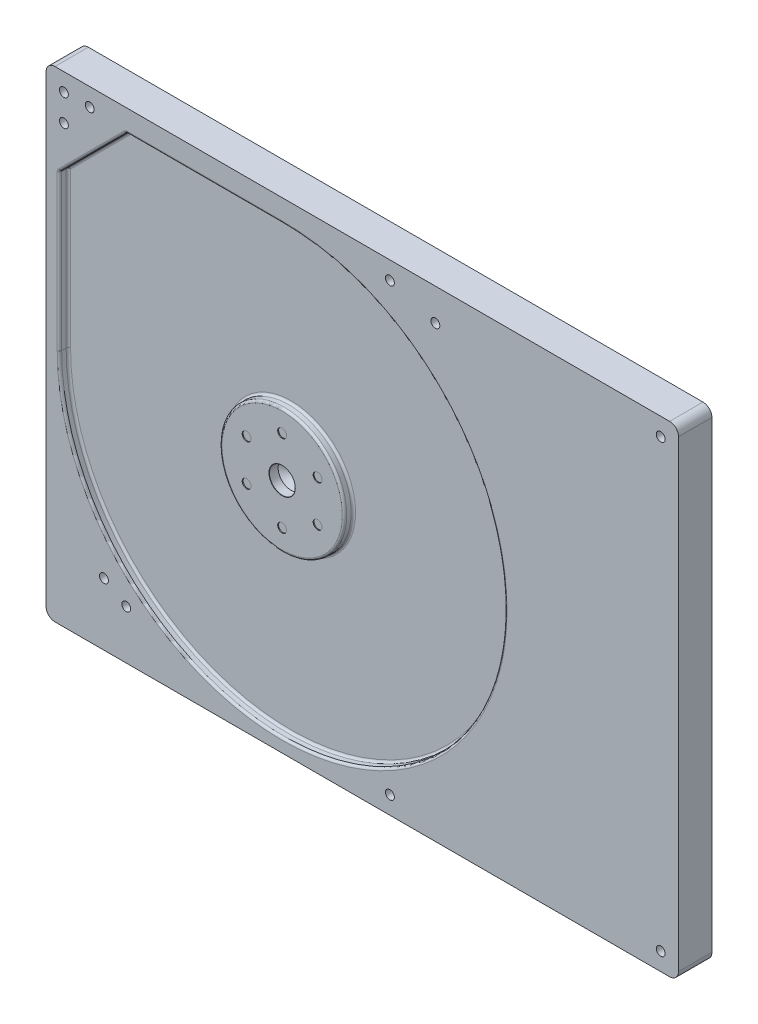
from build123d import *

# Parameters (mm, degrees)
SKETCH1_W                        = 71
SKETCH1_H                        = 54
BOSS_EXTRUDE1_DEPTH              = 3.75
FILLET1_R                        = 1
SKETCH2_R                        = 7
CUT_EXTRUDE1_DEPTH               = 1
FILLET2_R                        = 0.25
SKETCH3_R                        = 0.5
CUT_EXTRUDE2_DEPTH               = 0.1
FILLET3_R                        = 0.25
M2_5_CLEARANCE_HOLE1_D           = 2.9
M2_5_CLEARANCE_HOLE1_DEPTH       = 1
M2_5_CLEARANCE_HOLE1_CSINK_D     = 2.95
M2_5_CLEARANCE_HOLE1_CSINK_ANGLE = 90
M2_5_CLEARANCE_HOLE1_TIP         = 0.871247898
M1_6_CLEARANCE_HOLE1_D           = 1


with BuildPart() as part:
    # Sketch1 → Boss-Extrude1 (new body)
    with BuildSketch(Plane.XY):
        Rectangle(SKETCH1_W, SKETCH1_H)
    extrude(amount=BOSS_EXTRUDE1_DEPTH)

    # Fillet1
    fillet1_edges = [part.edges().sort_by_distance(p)[0] for p in [
        (35.5, -27, 1.875),
        (-35.5, -27, 1.875),
        (-35.5, 27, 1.875),
        (35.5, 27, 1.875),
    ]]
    fillet(fillet1_edges, radius=FILLET1_R)

    # Sketch2 → Cut-Extrude1 (cut)
    with BuildSketch(Plane.XY.offset(3.75)):
        with BuildLine():
            Line((-34, -0.5), (-34, 17))
            Line((-34, 17), (-26.5, 24.5))
            Line((-26.5, 24.5), (-9, 24.5))
            ThreePointArc((-9, 24.5), (8.67766953, -18.17766953), (-34, -0.5))
        make_face()
        with Locations((-9, -0.5)):
            Circle(SKETCH2_R, mode=Mode.SUBTRACT)
    extrude(amount=-CUT_EXTRUDE1_DEPTH, mode=Mode.SUBTRACT)

    # Fillet2
    fillet2_edges = [part.edges().sort_by_distance(p)[0] for p in [
        (-16, -0.5, 3.75),
    ]]
    fillet(fillet2_edges, radius=FILLET2_R)

    # Sketch3 → Cut-Extrude2 (cut)
    with BuildSketch(Plane.XY.offset(3.75)):
        with Locations((-9, 4.1)):
            Circle(SKETCH3_R)
        with Locations((-12.983716857, 1.8)):
            Circle(SKETCH3_R)
        with Locations((-12.983716857, -2.8)):
            Circle(SKETCH3_R)
        with Locations((-9, -5.1)):
            Circle(SKETCH3_R)
        with Locations((-5.016283143, -2.8)):
            Circle(SKETCH3_R)
        with Locations((-5.016283143, 1.8)):
            Circle(SKETCH3_R)
    extrude(amount=-CUT_EXTRUDE2_DEPTH, mode=Mode.SUBTRACT)

    # Fillet3
    fillet3_edges = [part.edges().sort_by_distance(p)[0] for p in [
        (8.67766953, -18.17766953, 2.75),
        (-34, 8.25, 2.75),
        (-30.25, 20.75, 2.75),
        (-34, 17, 3.25),
        (-17.75, 24.5, 2.75),
        (-26.5, 24.5, 3.25),
        (-16, -0.5, 2.75),
        (8.67766953, -18.17766953, 3.75),
        (-17.75, 24.5, 3.75),
        (-30.25, 20.75, 3.75),
        (-34, 8.25, 3.75),
    ]]
    fillet(fillet3_edges, radius=FILLET3_R)

    # M2.5 Clearance Hole1
    with Locations(Plane.XY.offset(3.75)):
        with Locations((-9, -0.5)):
            CounterSinkHole(M2_5_CLEARANCE_HOLE1_D / 2, M2_5_CLEARANCE_HOLE1_CSINK_D / 2, depth=M2_5_CLEARANCE_HOLE1_DEPTH, counter_sink_angle=M2_5_CLEARANCE_HOLE1_CSINK_ANGLE)
            with Locations((0, 0, -(M2_5_CLEARANCE_HOLE1_DEPTH + M2_5_CLEARANCE_HOLE1_TIP / 2))):  # 118° drill point
                Cone(0, M2_5_CLEARANCE_HOLE1_D / 2, M2_5_CLEARANCE_HOLE1_TIP, mode=Mode.SUBTRACT)

    # M1.6 Clearance Hole1 (through all)
    with Locations(Plane.XY.offset(3.75)):
        with Locations((-169.780661566, 67.45785255), (-33.5, 22), (-30.6, 25), (3.1, 25), (33.5, 25), (8.2, 23.4), (33.5, -25), (3.1, -25), (-26.5, -21.5), (-29, -20), (-33.5, 25)):
            Hole(M1_6_CLEARANCE_HOLE1_D / 2)


solid = part.part
